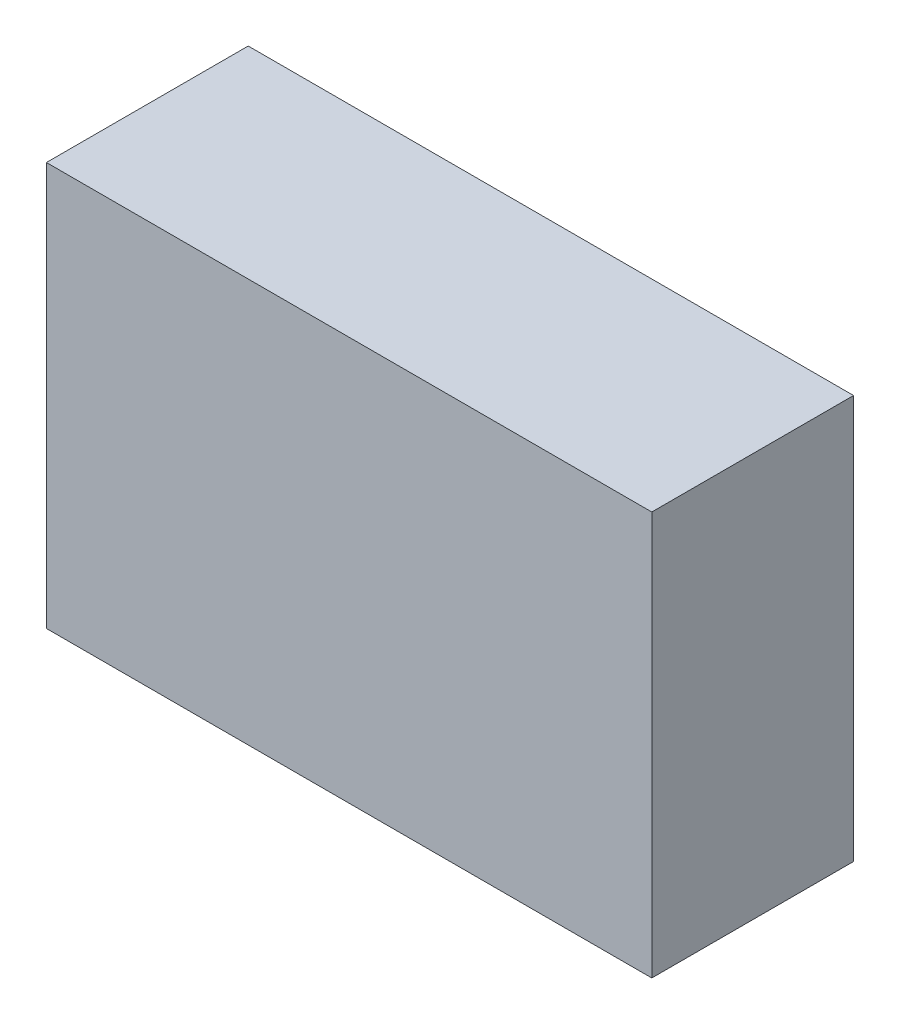
from build123d import *

# Parameters (mm, degrees)
CROQUIS1_W              = 45
CROQUIS1_H              = 15
SALIENTE_EXTRUIR1_DEPTH = 30


with BuildPart() as part:
    # Croquis1 → Saliente-Extruir1 (new body)
    with BuildSketch(Plane(origin=(0, 0, 0), x_dir=(1, 0, 0), z_dir=(0, 1, 0))):
        Rectangle(CROQUIS1_W, CROQUIS1_H)
    extrude(amount=SALIENTE_EXTRUIR1_DEPTH)


solid = part.part
